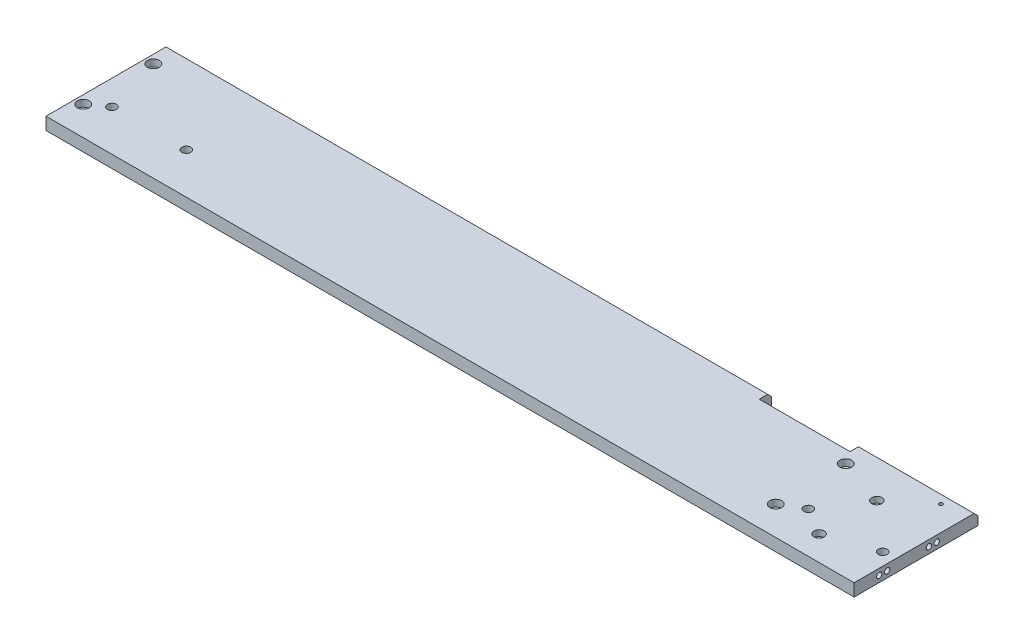
from build123d import *

# Parameters (mm, degrees)
BOSS_EXTRUDE1_DEPTH = 9.55
CHAMFER1_SIZE       = 3
CUT_EXTRUDE1_REACH  = 630.926
SKETCH2_R           = 2.565
SKETCH2_R_2         = 3.445
SKETCH2_R_3         = 2.795
SKETCH2_R_4         = 2.48
SKETCH2_R_5         = 1.385
SKETCH3_R           = 4.61
CUT_EXTRUDE2_DEPTH  = 5.2
SKETCH4_R           = 3.98
CUT_EXTRUDE3_DEPTH  = 4.54
SKETCH5_R           = 3.445
CUT_EXTRUDE4_DEPTH  = 7.68
SKETCH6_R           = 4
SKETCH6_R_2         = 2.565
BOSS_EXTRUDE2_DEPTH = 2.5
SKETCH7_R           = 2.065
CUT_EXTRUDE5_DEPTH  = 18.99
SKETCH8_R           = 2.065
CUT_EXTRUDE6_DEPTH  = 18.7


with BuildPart() as part:
    # Sketch1 → Boss-Extrude1 (new body)
    with BuildSketch(Plane(origin=(0, 0, 0), x_dir=(1, 0, 0), z_dir=(0, 1, 0))):
        Polygon((532.64, 0), (621.59, 0), (621.59, -95.3), (0, -95.3), (0, 0), (462.84, 0), (462.84, -9.5), (532.64, -9.5), align=None)
    extrude(amount=BOSS_EXTRUDE1_DEPTH)

    # Chamfer1
    chamfer1_edges = [part.edges().sort_by_distance(p)[0] for p in [
        (577.115, 9.55, 0),
        (231.42, 9.55, 0),
    ]]
    chamfer(chamfer1_edges, length=CHAMFER1_SIZE)

    # Sketch2 → Cut-Extrude1 (cut, up to next)
    with BuildSketch(Plane(origin=(0, 9.55, 0), x_dir=(-1, 0, 0), z_dir=(0, 1, 0)), mode=Mode.PRIVATE) as cut_extrude1_sk1:
        with Locations(Location((-611.995, 63.695, 0), (0, 0, 90))):
            Circle(SKETCH2_R)
    cut_extrude1_tool1 = extrude(cut_extrude1_sk1.sketch, amount=-CUT_EXTRUDE1_REACH, mode=Mode.PRIVATE) & part.part
    # Sketch2 → Cut-Extrude1 (cut, up to next)
    with BuildSketch(Plane(origin=(0, 9.55, 0), x_dir=(-1, 0, 0), z_dir=(0, 1, 0)), mode=Mode.PRIVATE) as cut_extrude1_sk2:
        with Locations(Location((-554.785, 63.695, 0), (0, 0, 90))):
            Circle(SKETCH2_R_2)
    cut_extrude1_tool2 = extrude(cut_extrude1_sk2.sketch, amount=-CUT_EXTRUDE1_REACH, mode=Mode.PRIVATE) & part.part
    # Sketch2 → Cut-Extrude1 (cut, up to next)
    with BuildSketch(Plane(origin=(0, 9.55, 0), x_dir=(-1, 0, 0), z_dir=(0, 1, 0)), mode=Mode.PRIVATE) as cut_extrude1_sk3:
        with Locations(Location((-6.42, 19.16, 0), (0, 0, 90))):
            Circle(SKETCH2_R_3)
    cut_extrude1_tool3 = extrude(cut_extrude1_sk3.sketch, amount=-CUT_EXTRUDE1_REACH, mode=Mode.PRIVATE) & part.part
    # Sketch2 → Cut-Extrude1 (cut, up to next)
    with BuildSketch(Plane(origin=(0, 9.55, 0), x_dir=(-1, 0, 0), z_dir=(0, 1, 0)), mode=Mode.PRIVATE) as cut_extrude1_sk4:
        with Locations(Location((-6.42, 73.05, 0), (0, 0, 90))):
            Circle(SKETCH2_R_3)
    cut_extrude1_tool4 = extrude(cut_extrude1_sk4.sketch, amount=-CUT_EXTRUDE1_REACH, mode=Mode.PRIVATE) & part.part
    # Sketch2 → Cut-Extrude1 (cut, up to next)
    with BuildSketch(Plane(origin=(0, 9.55, 0), x_dir=(-1, 0, 0), z_dir=(0, 1, 0)), mode=Mode.PRIVATE) as cut_extrude1_sk5:
        with Locations(Location((-575.61, 76.28, 0), (0, 0, 90))):
            Circle(SKETCH2_R_4)
    cut_extrude1_tool5 = extrude(cut_extrude1_sk5.sketch, amount=-CUT_EXTRUDE1_REACH, mode=Mode.PRIVATE) & part.part
    # Sketch2 → Cut-Extrude1 (cut, up to next)
    with BuildSketch(Plane(origin=(0, 9.55, 0), x_dir=(-1, 0, 0), z_dir=(0, 1, 0)), mode=Mode.PRIVATE) as cut_extrude1_sk6:
        with Locations(Location((-575.61, 31.84, 0), (0, 0, 90))):
            Circle(SKETCH2_R_4)
    cut_extrude1_tool6 = extrude(cut_extrude1_sk6.sketch, amount=-CUT_EXTRUDE1_REACH, mode=Mode.PRIVATE) & part.part
    # Sketch2 → Cut-Extrude1 (cut, up to next)
    with BuildSketch(Plane(origin=(0, 9.55, 0), x_dir=(-1, 0, 0), z_dir=(0, 1, 0)), mode=Mode.PRIVATE) as cut_extrude1_sk7:
        with Locations(Location((-539.07, 73.05, 0), (0, 0, 90))):
            Circle(SKETCH2_R_3)
    cut_extrude1_tool7 = extrude(cut_extrude1_sk7.sketch, amount=-CUT_EXTRUDE1_REACH, mode=Mode.PRIVATE) & part.part
    # Sketch2 → Cut-Extrude1 (cut, up to next)
    with BuildSketch(Plane(origin=(0, 9.55, 0), x_dir=(-1, 0, 0), z_dir=(0, 1, 0)), mode=Mode.PRIVATE) as cut_extrude1_sk8:
        with Locations(Location((-539.07, 19.16, 0), (0, 0, 90))):
            Circle(SKETCH2_R_3)
    cut_extrude1_tool8 = extrude(cut_extrude1_sk8.sketch, amount=-CUT_EXTRUDE1_REACH, mode=Mode.PRIVATE) & part.part
    # Sketch2 → Cut-Extrude1 (cut, up to next)
    with BuildSketch(Plane(origin=(0, 9.55, 0), x_dir=(-1, 0, 0), z_dir=(0, 1, 0)), mode=Mode.PRIVATE) as cut_extrude1_sk9:
        with Locations(Location((-19.135, 63.695, 0), (0, 0, 90))):
            Circle(SKETCH2_R)
    cut_extrude1_tool9 = extrude(cut_extrude1_sk9.sketch, amount=-CUT_EXTRUDE1_REACH, mode=Mode.PRIVATE) & part.part
    # Sketch2 → Cut-Extrude1 (cut, up to next)
    with BuildSketch(Plane(origin=(0, 9.55, 0), x_dir=(-1, 0, 0), z_dir=(0, 1, 0)), mode=Mode.PRIVATE) as cut_extrude1_sk10:
        with Locations(Location((-76.345, 63.695, 0), (0, 0, 90))):
            Circle(SKETCH2_R)
    cut_extrude1_tool10 = extrude(cut_extrude1_sk10.sketch, amount=-CUT_EXTRUDE1_REACH, mode=Mode.PRIVATE) & part.part
    # Sketch2 → Cut-Extrude1 (cut, up to next)
    with BuildSketch(Plane(origin=(0, 9.55, 0), x_dir=(-1, 0, 0), z_dir=(0, 1, 0)), mode=Mode.PRIVATE) as cut_extrude1_sk11:
        with Locations(Location((-602.545, 9.5, 0), (0, 0, 90))):
            Circle(SKETCH2_R_5)
    cut_extrude1_tool11 = extrude(cut_extrude1_sk11.sketch, amount=-CUT_EXTRUDE1_REACH, mode=Mode.PRIVATE) & part.part
    add(cut_extrude1_tool1.solids().sort_by_distance((611.995, 9.55, 63.695))[0], mode=Mode.SUBTRACT)
    add(cut_extrude1_tool2.solids().sort_by_distance((554.785, 9.55, 63.695))[0], mode=Mode.SUBTRACT)
    add(cut_extrude1_tool3.solids().sort_by_distance((6.42, 9.55, 19.16))[0], mode=Mode.SUBTRACT)
    add(cut_extrude1_tool4.solids().sort_by_distance((6.42, 9.55, 73.05))[0], mode=Mode.SUBTRACT)
    add(cut_extrude1_tool5.solids().sort_by_distance((575.61, 9.55, 76.28))[0], mode=Mode.SUBTRACT)
    add(cut_extrude1_tool6.solids().sort_by_distance((575.61, 9.55, 31.84))[0], mode=Mode.SUBTRACT)
    add(cut_extrude1_tool7.solids().sort_by_distance((539.07, 9.55, 73.05))[0], mode=Mode.SUBTRACT)
    add(cut_extrude1_tool8.solids().sort_by_distance((539.07, 9.55, 19.16))[0], mode=Mode.SUBTRACT)
    add(cut_extrude1_tool9.solids().sort_by_distance((19.135, 9.55, 63.695))[0], mode=Mode.SUBTRACT)
    add(cut_extrude1_tool10.solids().sort_by_distance((76.345, 9.55, 63.695))[0], mode=Mode.SUBTRACT)
    add(cut_extrude1_tool11.solids().sort_by_distance((602.545, 9.55, 9.5))[0], mode=Mode.SUBTRACT)

    # Sketch3 → Cut-Extrude2 (cut)
    with BuildSketch(Plane(origin=(0, 9.55, 0), x_dir=(-1, 0, 0), z_dir=(0, 1, 0))):
        with Locations(Location((-6.42, 19.16, 0), (0, 0, 90))):
            Circle(SKETCH3_R)
        with Locations(Location((-6.42, 73.05, 0), (0, 0, 90))):
            Circle(SKETCH3_R)
        with Locations(Location((-539.07, 19.16, 0), (0, 0, 90))):
            Circle(SKETCH3_R)
        with Locations(Location((-539.07, 73.05, 0), (0, 0, 90))):
            Circle(SKETCH3_R)
    extrude(amount=-CUT_EXTRUDE2_DEPTH, mode=Mode.SUBTRACT)

    # Sketch4 → Cut-Extrude3 (cut)
    with BuildSketch(Plane(origin=(0, 9.55, 0), x_dir=(-1, 0, 0), z_dir=(0, 1, 0))):
        with Locations(Location((-575.61, 31.84, 0), (0, 0, 90))):
            Circle(SKETCH4_R)
        with Locations(Location((-575.61, 76.28, 0), (0, 0, 90))):
            Circle(SKETCH4_R)
    extrude(amount=-CUT_EXTRUDE3_DEPTH, mode=Mode.SUBTRACT)

    # Sketch5 → Cut-Extrude4 (cut)
    with BuildSketch(Plane(origin=(0, 9.55, 0), x_dir=(-1, 0, 0), z_dir=(0, 1, 0))):
        with Locations(Location((-611.995, 63.695, 0), (0, 0, 90))):
            Circle(SKETCH5_R)
        with Locations(Location((-76.345, 63.695, 0), (0, 0, 90))):
            Circle(SKETCH5_R)
        with Locations(Location((-19.135, 63.695, 0), (0, 0, 90))):
            Circle(SKETCH5_R)
    extrude(amount=-CUT_EXTRUDE4_DEPTH, mode=Mode.SUBTRACT)

    # Sketch6 → Boss-Extrude2 (add)
    with BuildSketch(Plane.XZ):
        with Locations(Location((611.995, 63.695, 0), (0, 0, 90))):
            Circle(SKETCH6_R)
        with Locations(Location((611.995, 63.695, 0), (0, 0, 90))):
            Circle(SKETCH6_R_2, mode=Mode.SUBTRACT)
        with Locations(Location((76.345, 63.695, 0), (0, 0, 90))):
            Circle(SKETCH6_R)
        with Locations(Location((76.345, 63.695, 0), (0, 0, 90))):
            Circle(SKETCH6_R_2, mode=Mode.SUBTRACT)
        with Locations(Location((19.135, 63.695, 0), (0, 0, 90))):
            Circle(SKETCH6_R)
        with Locations(Location((19.135, 63.695, 0), (0, 0, 90))):
            Circle(SKETCH6_R_2, mode=Mode.SUBTRACT)
    extrude(amount=BOSS_EXTRUDE2_DEPTH)

    # Sketch7 → Cut-Extrude5 (cut)
    with BuildSketch(Plane(origin=(0, 0, 9.5), x_dir=(-1, 0, 0), z_dir=(0, 0, -1))):
        with Locations((-507.305, 4.775)):
            Circle(SKETCH7_R)
        with Locations((-475.355, 4.775)):
            Circle(SKETCH7_R)
    extrude(amount=-CUT_EXTRUDE5_DEPTH, mode=Mode.SUBTRACT)

    # Sketch8 → Cut-Extrude6 (cut)
    with BuildSketch(Plane(origin=(621.59, 0, 0), x_dir=(0, 0, -1), z_dir=(1, 0, 0))):
        with Locations((-31.685, 4.775)):
            Circle(SKETCH8_R)
        with Locations((-37.755, 4.775)):
            Circle(SKETCH8_R)
        with Locations((-69.865, 4.775)):
            Circle(SKETCH8_R)
        with Locations((-75.935, 4.775)):
            Circle(SKETCH8_R)
    extrude(amount=-CUT_EXTRUDE6_DEPTH, mode=Mode.SUBTRACT)


solid = part.part
